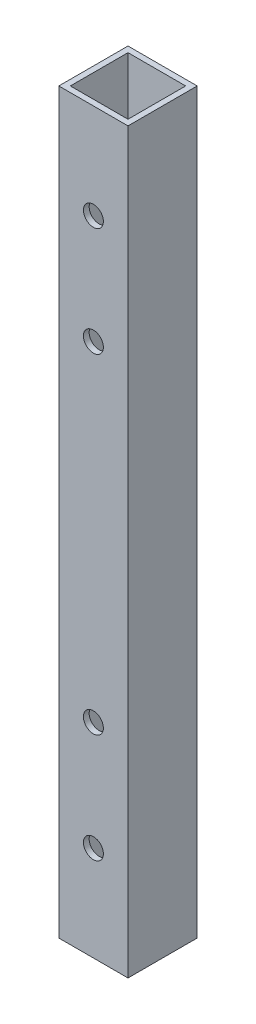
from build123d import *

# Parameters (mm, degrees)
SKETCH1_W           = 19.05
SKETCH1_H           = 19.05
SKETCH1_W_2         = 15.875
SKETCH1_H_2         = 15.875
BOSS_EXTRUDE1_DEPTH = 914.4
SKETCH2_R           = 2.75
CUT_EXTRUDE1_DEPTH  = 20.05
CUT_EXTRUDE2_REACH  = 21.05
SKETCH3_R           = 4.255
SKETCH4_OUTSIDE_W   = 204.01
SKETCH4_OUTSIDE_H   = 1099.36
SKETCH4_OUTSIDE_W_2 = 19.05
SKETCH4_OUTSIDE_H_2 = 203.2
CUT_EXTRUDE3_DEPTH  = 20.05
SKETCH5_R           = 2.75
CUT_EXTRUDE4_DEPTH  = 20.05


with BuildPart() as part:
    # Sketch1 → Boss-Extrude1 (new body)
    with BuildSketch(Plane(origin=(0, 0, 0), x_dir=(1, 0, 0), z_dir=(0, 1, 0))):
        with Locations((9.525, 9.525)):
            Rectangle(SKETCH1_W, SKETCH1_H)
        with Locations((9.525, 9.525)):
            Rectangle(SKETCH1_W_2, SKETCH1_H_2, mode=Mode.SUBTRACT)
    extrude(amount=BOSS_EXTRUDE1_DEPTH)

    # Sketch2 → Cut-Extrude1 (cut, through all)
    with BuildSketch(Plane.XY):
        with Locations((9.525, 906.4)):
            Circle(SKETCH2_R)
        with Locations((9.525, 891.4)):
            Circle(SKETCH2_R)
    extrude(amount=-CUT_EXTRUDE1_DEPTH, mode=Mode.SUBTRACT)

    # Sketch3 → Cut-Extrude2 (cut, up to next)
    with BuildSketch(Plane(origin=(0, 0, -19.05), x_dir=(-1, 0, 0), z_dir=(0, 0, -1)), mode=Mode.PRIVATE) as cut_extrude2_sk1:
        with Locations((-9.525, 906.4)):
            Circle(SKETCH3_R)
    cut_extrude2_tool1 = extrude(cut_extrude2_sk1.sketch, amount=-CUT_EXTRUDE2_REACH, mode=Mode.PRIVATE) & part.part
    add(cut_extrude2_tool1.solids().sort_by_distance((9.525, 906.4, -19.05))[0], mode=Mode.SUBTRACT)
    # Sketch3 → Cut-Extrude2 (cut, up to next)
    with BuildSketch(Plane(origin=(0, 0, -19.05), x_dir=(-1, 0, 0), z_dir=(0, 0, -1)), mode=Mode.PRIVATE) as cut_extrude2_sk2:
        with Locations((-9.525, 891.4)):
            Circle(SKETCH3_R)
    cut_extrude2_tool2 = extrude(cut_extrude2_sk2.sketch, amount=-CUT_EXTRUDE2_REACH, mode=Mode.PRIVATE) & part.part
    add(cut_extrude2_tool2.solids().sort_by_distance((9.525, 891.4, -19.05))[0], mode=Mode.SUBTRACT)

    # Sketch4 outside → Cut-Extrude3 (cut, through all)
    with BuildSketch(Plane.XY):
        with Locations((9.525, 457.2)):
            Rectangle(SKETCH4_OUTSIDE_W, SKETCH4_OUTSIDE_H)
        with Locations((9.525, 660.4)):
            Rectangle(SKETCH4_OUTSIDE_W_2, SKETCH4_OUTSIDE_H_2, mode=Mode.SUBTRACT)
    extrude(amount=-CUT_EXTRUDE3_DEPTH, mode=Mode.SUBTRACT)

    # Sketch5 → Cut-Extrude4 (cut, through all)
    with BuildSketch(Plane.XY):
        with Locations((9.52, 735.8)):
            Circle(SKETCH5_R)
        with Locations((9.52, 705.8)):
            Circle(SKETCH5_R)
        with Locations((9.52, 585)):
            Circle(SKETCH5_R)
        with Locations((9.52, 615)):
            Circle(SKETCH5_R)
    extrude(amount=-CUT_EXTRUDE4_DEPTH, mode=Mode.SUBTRACT)


solid = part.part
